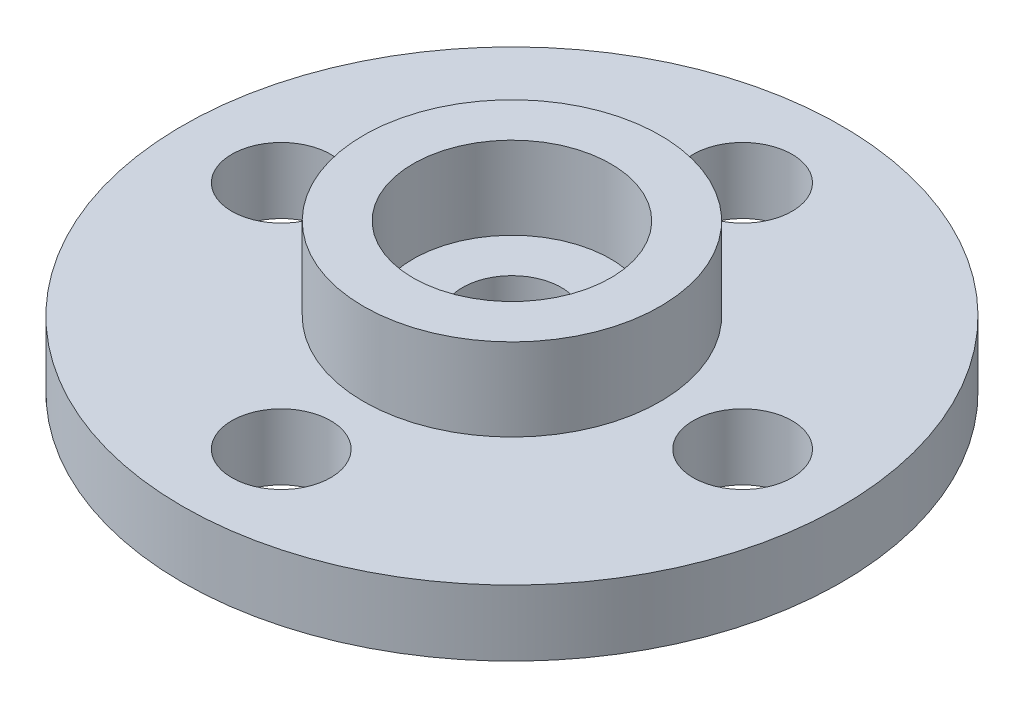
from build123d import *

# Parameters (mm, degrees)
SKETCH1_R           = 10
SKETCH1_R_2         = 1.5
BOSS_EXTRUDE1_DEPTH = 2
SKETCH2_R           = 4.5
SKETCH2_R_2         = 3
BOSS_EXTRUDE2_DEPTH = 2.5


with BuildPart() as part:
    # Sketch1 → Boss-Extrude1 (new body)
    with BuildSketch(Plane(origin=(0, 0, 0), x_dir=(1, 0, 0), z_dir=(0, 1, 0))):
        Circle(SKETCH1_R)
        with Locations((0, -7)):
            Circle(SKETCH1_R_2, mode=Mode.SUBTRACT)
        with Locations((-7, 0)):
            Circle(SKETCH1_R_2, mode=Mode.SUBTRACT)
        with Locations((0, 7)):
            Circle(SKETCH1_R_2, mode=Mode.SUBTRACT)
        with Locations((7, 0)):
            Circle(SKETCH1_R_2, mode=Mode.SUBTRACT)
        Circle(SKETCH1_R_2, mode=Mode.SUBTRACT)
    extrude(amount=BOSS_EXTRUDE1_DEPTH)

    # Sketch2 → Boss-Extrude2 (add)
    with BuildSketch(Plane(origin=(0, 2, 0), x_dir=(1, 0, 0), z_dir=(0, 1, 0))):
        Circle(SKETCH2_R)
        Circle(SKETCH2_R_2, mode=Mode.SUBTRACT)
    extrude(amount=BOSS_EXTRUDE2_DEPTH)


solid = part.part
